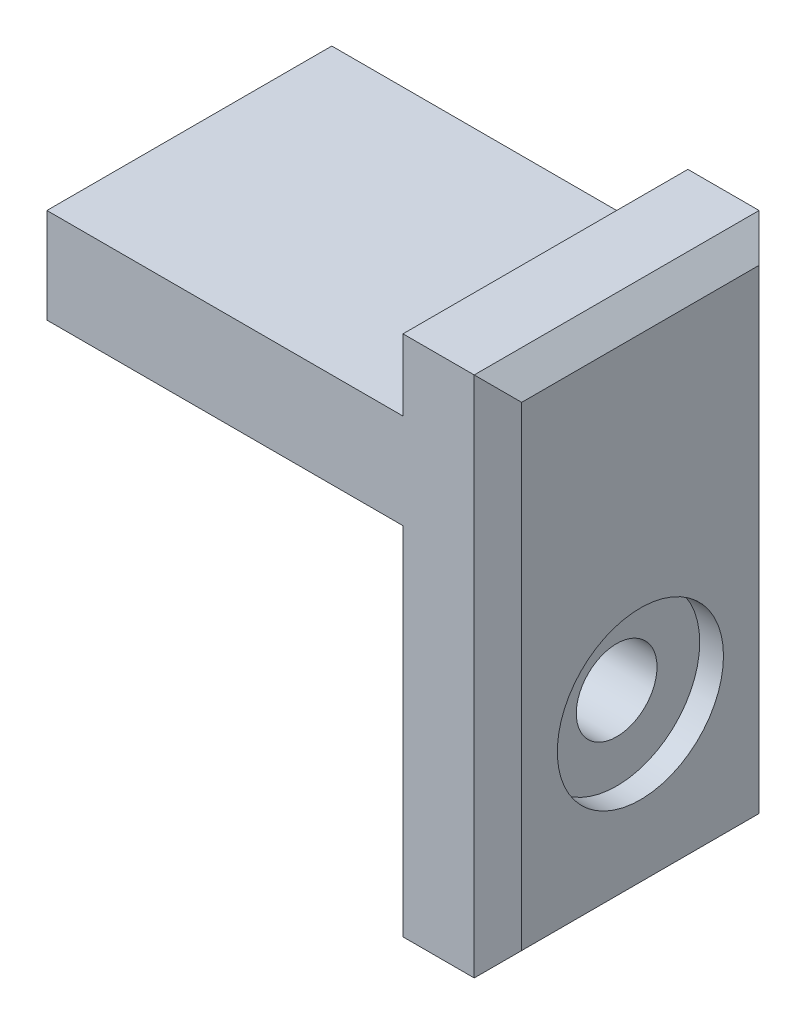
from build123d import *

# Parameters (mm, degrees)
BOSS_EXTRUDE1_DEPTH = 12
SKETCH2_R           = 1.7
CUT_EXTRUDE1_DEPTH  = 12
SKETCH3_R           = 3.5
CUT_EXTRUDE2_DEPTH  = 1
CHAMFER1_SIZE       = 1


with BuildPart() as part:
    # Sketch1 → Boss-Extrude1 (new body)
    with BuildSketch(Plane.XY):
        Polygon((0, 19), (15, 19), (15, 22), (19, 22), (19, 19), (19, 0), (15, 0), (15, 15), (0, 15), align=None)
    extrude(amount=BOSS_EXTRUDE1_DEPTH)

    # Sketch2 → Cut-Extrude1 (cut)
    with BuildSketch(Plane.ZY.offset(-15)):
        with Locations((6, 7.5)):
            Circle(SKETCH2_R)
    extrude(amount=-CUT_EXTRUDE1_DEPTH, mode=Mode.SUBTRACT)

    # Sketch3 → Cut-Extrude2 (cut)
    with BuildSketch(Plane(origin=(19, 0, 0), x_dir=(0, 0, -1), z_dir=(1, 0, 0))):
        with Locations((-6, 7.5)):
            Circle(SKETCH3_R)
    extrude(amount=-CUT_EXTRUDE2_DEPTH, mode=Mode.SUBTRACT)

    # Chamfer1
    chamfer1_edges = [part.edges().sort_by_distance(p)[0] for p in [
        (19, 11, 12),
        (19, 11, 0),
        (19, 22, 6),
        (19, 0, 6),
    ]]
    chamfer(chamfer1_edges, length=CHAMFER1_SIZE)


solid = part.part
